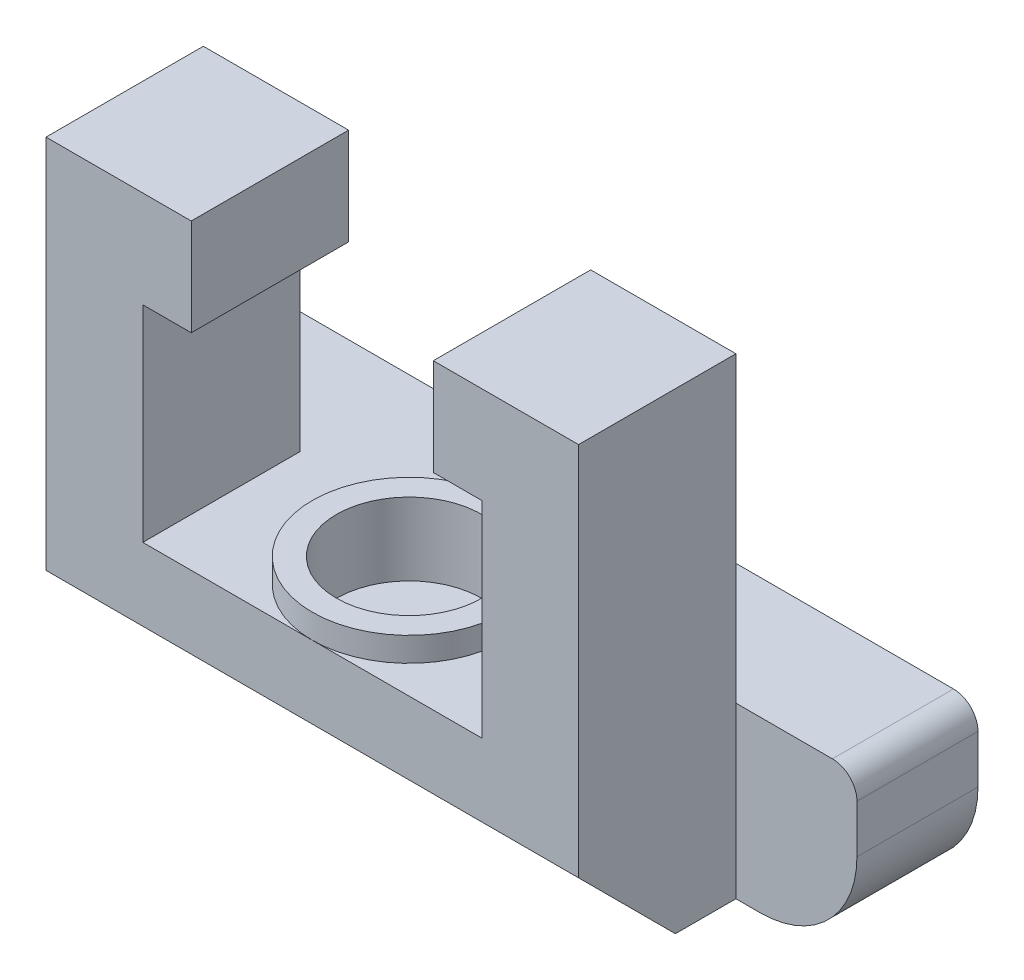
from build123d import *

# Parameters (mm, degrees)
BOSS_EXTRUDE1_DEPTH = 5.24256
BOSS_EXTRUDE2_DEPTH = 4.03352
CHAMFER1_SIZE       = 3.2258
SKETCH3_R           = 3.2258
BOSS_EXTRUDE3_DEPTH = 0.80772
SKETCH4_R           = 2.42062
CUT_EXTRUDE1_DEPTH  = 2.42062


with BuildPart() as part:
    # Sketch1 → Boss-Extrude1 (new body)
    with BuildSketch(Plane.XY):
        Polygon((-8.87222, -7.86384), (8.87222, -7.86384), (8.87222, 7.86384), (4.03225, 7.86384), (4.03225, 4.63804), (5.64642, 4.63804), (5.64642, -2.21742), (-5.64642, -2.21742), (-5.64642, 4.63804), (-4.03225, 4.63804), (-4.03225, 7.86384), (-8.87222, 7.86384), align=None)
    extrude(amount=BOSS_EXTRUDE1_DEPTH)

    # Sketch2 → Boss-Extrude2 (add)
    with BuildSketch(Plane(origin=(0, 0, 0), x_dir=(-1, 0, 0), z_dir=(0, 0, -1))):
        with BuildLine():
            Line((-12.088220572, -2.21742), (12.088220572, -2.21742))
            ThreePointArc((12.088220572, -2.21742), (12.665396078, -2.456493922), (12.90447, -3.033669428))
            Line((12.90447, -3.033669428), (12.90447, -4.63804))
            ThreePointArc((12.90447, -4.63804), (11.959655055, -6.919025055), (9.67867, -7.86384))
            Line((9.67867, -7.86384), (-9.67867, -7.86384))
            ThreePointArc((-9.67867, -7.86384), (-11.959655055, -6.919025055), (-12.90447, -4.63804))
            Line((-12.90447, -4.63804), (-12.90447, -3.033669428))
            ThreePointArc((-12.90447, -3.033669428), (-12.665396078, -2.456493922), (-12.088220572, -2.21742))
        make_face()
    extrude(amount=BOSS_EXTRUDE2_DEPTH)

    # Chamfer1
    chamfer1_edges = [part.edges().sort_by_distance(p)[0] for p in [
        (0, -7.86384, 5.24256),
    ]]
    chamfer(chamfer1_edges, length=CHAMFER1_SIZE)

    # Sketch3 → Boss-Extrude3 (add)
    with BuildSketch(Plane(origin=(0, -2.21742, 0), x_dir=(1, 0, 0), z_dir=(0, 1, 0))):
        with Locations((0, -2.01676)):
            Circle(SKETCH3_R)
    extrude(amount=BOSS_EXTRUDE3_DEPTH)

    # Sketch4 → Cut-Extrude1 (cut)
    with BuildSketch(Plane(origin=(0, -1.4097, 0), x_dir=(1, 0, 0), z_dir=(0, 1, 0))):
        with Locations((0, -2.01676)):
            Circle(SKETCH4_R)
    extrude(amount=-CUT_EXTRUDE1_DEPTH, mode=Mode.SUBTRACT)


solid = part.part
